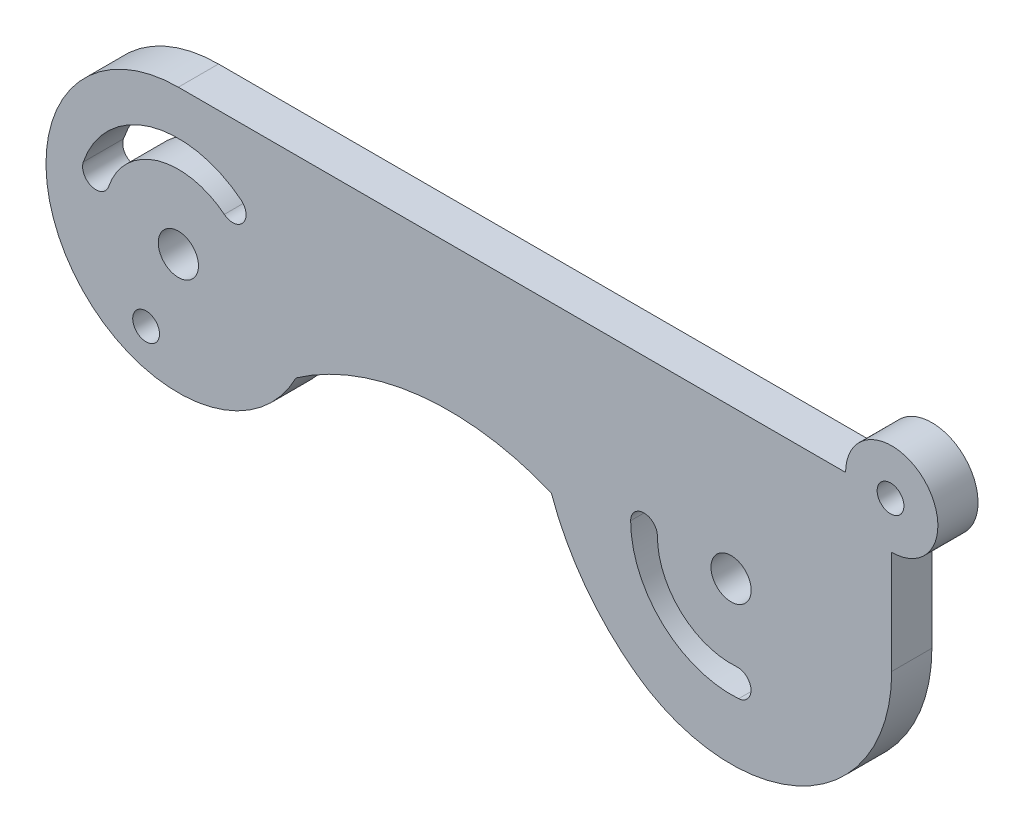
from build123d import *

# Parameters (mm, degrees)
SKETCH1_R           = 1
SKETCH1_R_2         = 1.5
BOSS_EXTRUDE1_DEPTH = 3
SKETCH2_R           = 1
CUT_EXTRUDE1_DEPTH  = 10


with BuildPart() as part:
    # Sketch1 → Boss-Extrude1 (new body)
    with BuildSketch(Plane.XY):
        with BuildLine():
            Line((56.489085284, -2.807723586), (56.489085284, -10.511796182))
            ThreePointArc((56.489085284, -10.511796182), (49.919430424, -21.212793876), (37.403860007, -20.196814652))
            ThreePointArc((37.403860007, -20.196814652), (33.591182056, -16.415053625), (31.06380939, -11.676845415))
            ThreePointArc((31.06380939, -11.676845415), (21.265519298, -10.288514848), (12.001109648, -13.767690656))
            ThreePointArc((12.001109648, -13.767690656), (-5.229619348, -14.397609216), (3.208983014, 0.638507613))
            Line((3.208983014, 0.638507613), (53.042854085, 0.638507613))
            ThreePointArc((53.042854085, 0.638507613), (58.925938734, 3.075361063), (56.489085284, -2.807723586))
        make_face()
        with Locations((56.398708828, 0.638507613)):
            Circle(SKETCH1_R, mode=Mode.SUBTRACT)
        with Locations((44.489085284, -10.511796182)):
            Circle(SKETCH1_R_2, mode=Mode.SUBTRACT)
        with Locations((3.208983014, -10.169286947)):
            Circle(SKETCH1_R_2, mode=Mode.SUBTRACT)
        with BuildLine():
            ThreePointArc((38.989085284, -10.511796182), (40.749804307, -14.545129515), (44.90464084, -15.996074947))
            ThreePointArc((44.90464084, -15.996074947), (45.977337989, -16.917660986), (45.055751951, -17.990358135))
            ThreePointArc((45.055751951, -17.990358135), (39.39006577, -16.011796182), (36.989085284, -10.511796182))
            ThreePointArc((36.989085284, -10.511796182), (37.989085284, -9.511796182), (38.989085284, -10.511796182))
        make_face(mode=Mode.SUBTRACT)
        with BuildLine():
            ThreePointArc((6.641982325, -5.872251255), (1.667062363, -4.889847516), (-1.99710038, -8.395394139))
            ThreePointArc((-1.99710038, -8.395394139), (-3.266186962, -9.019428792), (-3.890221615, -7.75034221))
            ThreePointArc((-3.890221615, -7.75034221), (1.106363944, -2.970051359), (7.890345711, -4.309692822))
            ThreePointArc((7.890345711, -4.309692822), (8.047443234, -5.715153732), (6.641982325, -5.872251255))
        make_face(mode=Mode.SUBTRACT)
    extrude(amount=BOSS_EXTRUDE1_DEPTH)

    # Sketch2 → Cut-Extrude1 (cut)
    with BuildSketch(Plane.XY.offset(3)):
        with Locations((0.801619135, -16.035407907)):
            Circle(SKETCH2_R)
    extrude(amount=-CUT_EXTRUDE1_DEPTH, mode=Mode.SUBTRACT)


solid = part.part
